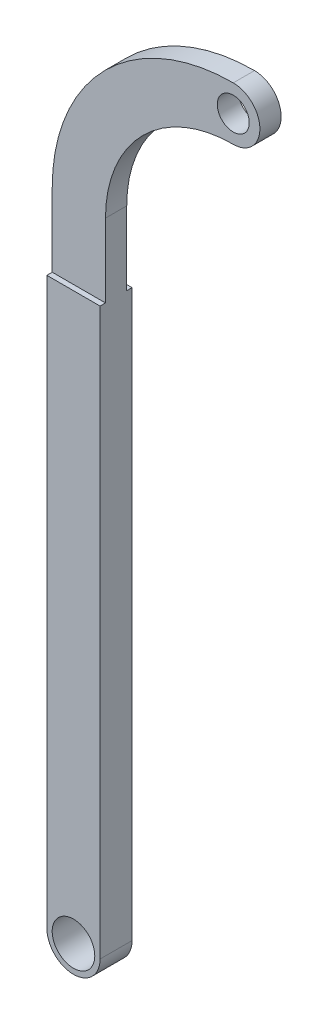
from build123d import *

# Parameters (mm, degrees)
SKETCH_1_R               = 2
SKETCH_1_R_2             = 1.5
EXTRUDE_1_DEPTH          = 3
SKETCH_2_W               = 0.5
SKETCH_2_H               = 23.89994555
SKETCH_2_W_2             = 0.589580916
CUT_EXTRUDE_1_DEPTH      = 18
CUT_EXTRUDE_1_DEPTH_BACK = 3.5


with BuildPart() as part:
    # 草图1 → 凸台-拉伸1 (new body)
    with BuildSketch(Plane.XY):
        with BuildLine():
            Line((-2.5, 0), (-2.5, 60))
            ThreePointArc((-2.5, 60), (2.47918472, 72.02081528), (14.5, 77))
            ThreePointArc((14.5, 77), (17, 74.5), (14.5, 72))
            ThreePointArc((14.5, 72), (6.014718626, 68.485281374), (2.5, 60))
            Line((2.5, 60), (2.5, 0))
            ThreePointArc((2.5, 0), (0, -2.5), (-2.5, 0))
        make_face()
        Circle(SKETCH_1_R, mode=Mode.SUBTRACT)
        with Locations((14.5, 74.5)):
            Circle(SKETCH_1_R_2, mode=Mode.SUBTRACT)
    extrude(amount=EXTRUDE_1_DEPTH)

    # 草图2 → 切除-拉伸1 (cut, two sides)
    with BuildSketch(Plane(origin=(0, 0, 0), x_dir=(0, 0, -1), z_dir=(1, 0, 0))) as cut_extrude_1_sk:
        with Locations((-0.25, 65.050027225)):
            Rectangle(SKETCH_2_W, SKETCH_2_H)
        with Locations((-2.790044711, 65.050027225)):
            Rectangle(SKETCH_2_W_2, SKETCH_2_H)
    extrude(amount=CUT_EXTRUDE_1_DEPTH, mode=Mode.SUBTRACT)
    extrude(cut_extrude_1_sk.sketch, amount=-CUT_EXTRUDE_1_DEPTH_BACK, mode=Mode.SUBTRACT)


solid = part.part
